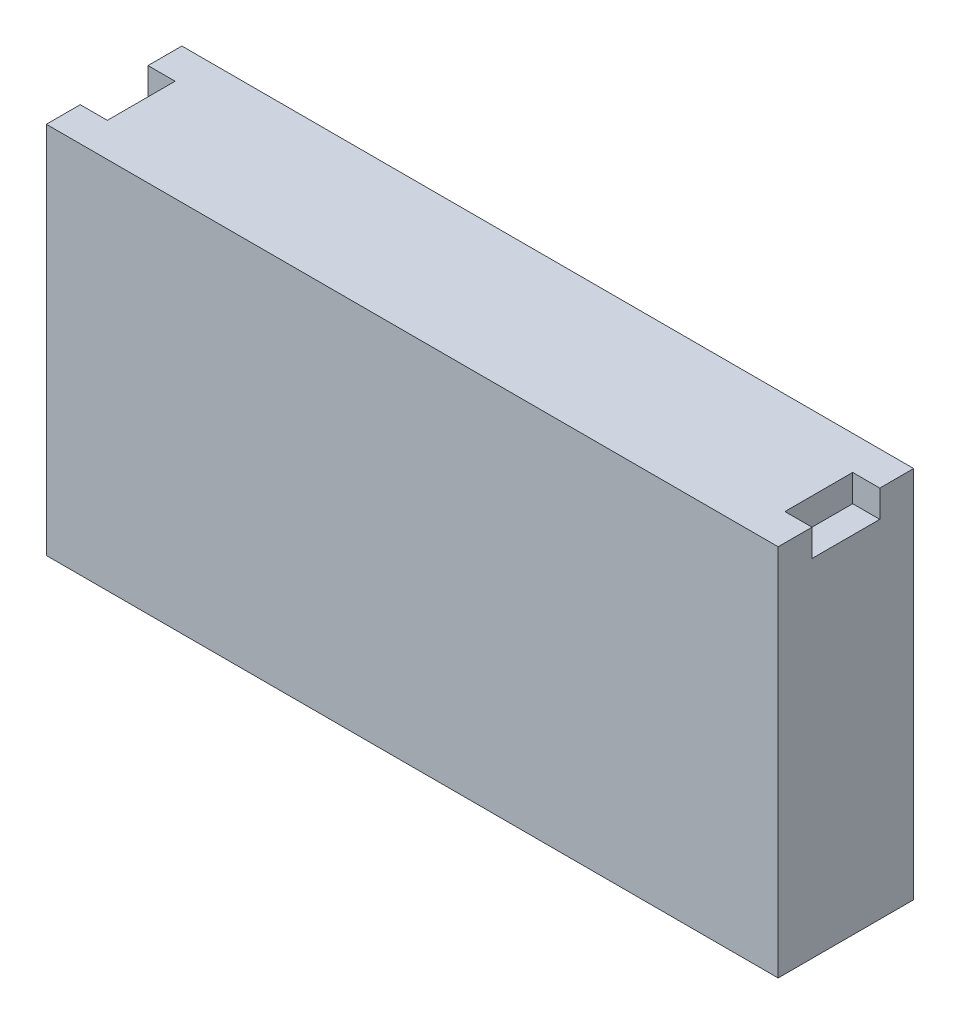
from build123d import *

# Parameters (mm, degrees)
SKETCH1_W           = 685.8
SKETCH1_H           = 127
BOSS_EXTRUDE1_DEPTH = 350
SKETCH2_W           = 25.4
SKETCH2_H           = 63.5
CUT_EXTRUDE2_DEPTH  = 25.4


with BuildPart() as part:
    # Sketch1 → Boss-Extrude1 (new body)
    with BuildSketch(Plane(origin=(0, 0, 0), x_dir=(1, 0, 0), z_dir=(0, 1, 0))):
        Rectangle(SKETCH1_W, SKETCH1_H)
    extrude(amount=BOSS_EXTRUDE1_DEPTH)

    # Sketch2 → Cut-Extrude2 (cut)
    with BuildSketch(Plane(origin=(0, 350, 0), x_dir=(1, 0, 0), z_dir=(0, 1, 0))):
        with Locations((-330.2, 0)):
            Rectangle(SKETCH2_W, SKETCH2_H)
        with Locations((330.2, 0)):
            Rectangle(SKETCH2_W, SKETCH2_H)
    extrude(amount=-CUT_EXTRUDE2_DEPTH, mode=Mode.SUBTRACT)


solid = part.part
